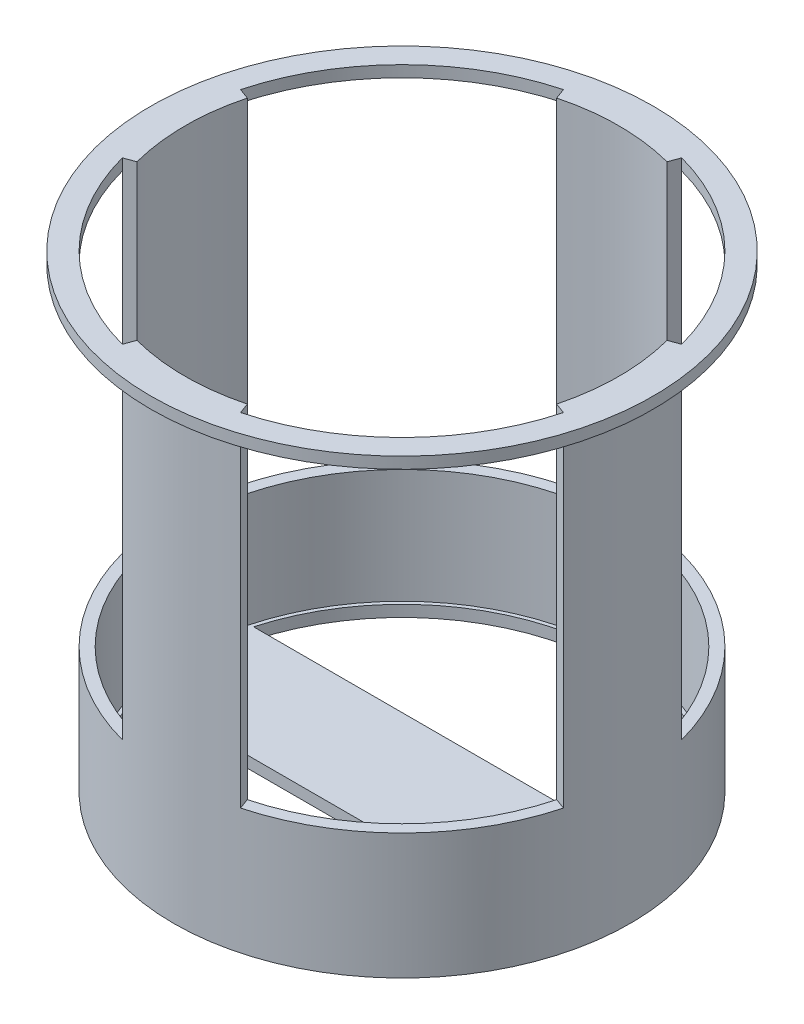
from build123d import *
from build123d.topology import SkipClean

# Parameters (mm, degrees)
SKETCH1_R           = 22
BOSS_EXTRUDE1_DEPTH = 1
SKETCH2_R           = 20
CUT_EXTRUDE1_DEPTH  = 1
SKETCH3_R           = 20
BOSS_EXTRUDE2_DEPTH = 1
BOSS_EXTRUDE3_REACH = 52.675
SKETCH5_R           = 20
SKETCH5_R_2         = 19.004147065
BOSS_EXTRUDE4_DEPTH = 10
CUT_EXTRUDE2_DEPTH  = 10


with BuildPart() as part:
    # Sketch1 → Boss-Extrude1 (new body)
    with BuildSketch(Plane(origin=(0, 0, 0), x_dir=(1, 0, 0), z_dir=(0, 1, 0))):
        with Locations(Location((0, 0, 0), (0, 0, 270))):
            Circle(SKETCH1_R)
    extrude(amount=BOSS_EXTRUDE1_DEPTH)

    # Sketch2 → Cut-Extrude1 (cut)
    with BuildSketch(Plane(origin=(0, 1, 0), x_dir=(1, 0, 0), z_dir=(0, 1, 0))):
        with Locations(Location((0, 0, 0), (0, 0, 270))):
            Circle(SKETCH2_R)
    extrude(amount=-CUT_EXTRUDE1_DEPTH, mode=Mode.SUBTRACT)

    # Boss-Extrude3: up to this face of the body (flat: up to its plane)
    boss_extrude3_end = Plane(part.part.faces().sort_by_distance((0, 1, -21.377746033))[0])
    # Sketch4 → Boss-Extrude3 (add, up to the picked face)
    with BuildSketch(Plane(origin=(0, -39, 0), x_dir=(1, 0, 0), z_dir=(0, 1, 0)), mode=Mode.PRIVATE) as boss_extrude3_sk1:
        with BuildLine():
            Line((-5.176380902, 19.318516526), (-4.834360759, 18.378823905))
            ThreePointArc((-4.834360759, 18.378823905), (-2.437308738, 18.847061792), (0, 19.004005159))
            ThreePointArc((0, 19.004005159), (2.437764249, 18.84700288), (4.835249142, 18.378590202))
            Line((4.835249142, 18.378590202), (5.176380902, 19.318516526))
            ThreePointArc((5.176380902, 19.318516526), (2.610523844, 19.828897227), (0, 20))
            ThreePointArc((0, 20), (-2.610523844, 19.828897227), (-5.176380902, 19.318516526))
        make_face()
    boss_extrude3_tool1 = split(extrude(boss_extrude3_sk1.sketch, amount=BOSS_EXTRUDE3_REACH, mode=Mode.PRIVATE), bisect_by=boss_extrude3_end, keep=Keep.BOTH, mode=Mode.PRIVATE)
    # Sketch4 → Boss-Extrude3 (add, up to the picked face)
    with BuildSketch(Plane(origin=(0, -39, 0), x_dir=(1, 0, 0), z_dir=(0, 1, 0)), mode=Mode.PRIVATE) as boss_extrude3_sk2:
        with BuildLine():
            Line((19.318516526, 5.176380902), (18.378823905, 4.834360759))
            ThreePointArc((18.378823905, 4.834360759), (18.847061792, 2.437308738), (19.004005159, 0))
            ThreePointArc((19.004005159, 0), (18.84700288, -2.437764249), (18.378590202, -4.835249142))
            Line((18.378590202, -4.835249142), (19.318516526, -5.176380902))
            ThreePointArc((19.318516526, -5.176380902), (19.828897227, -2.610523844), (20, 0))
            ThreePointArc((20, 0), (19.828897227, 2.610523844), (19.318516526, 5.176380902))
        make_face()
    boss_extrude3_tool2 = split(extrude(boss_extrude3_sk2.sketch, amount=BOSS_EXTRUDE3_REACH, mode=Mode.PRIVATE), bisect_by=boss_extrude3_end, keep=Keep.BOTH, mode=Mode.PRIVATE)
    # Sketch4 → Boss-Extrude3 (add, up to the picked face)
    with BuildSketch(Plane(origin=(0, -39, 0), x_dir=(1, 0, 0), z_dir=(0, 1, 0)), mode=Mode.PRIVATE) as boss_extrude3_sk3:
        with BuildLine():
            Line((5.176380902, -19.318516526), (4.834360759, -18.378823905))
            ThreePointArc((4.834360759, -18.378823905), (2.437308738, -18.847061792), (0, -19.004005159))
            ThreePointArc((0, -19.004005159), (-2.437764249, -18.84700288), (-4.835249142, -18.378590202))
            Line((-4.835249142, -18.378590202), (-5.176380902, -19.318516526))
            ThreePointArc((-5.176380902, -19.318516526), (-2.610523844, -19.828897227), (0, -20))
            ThreePointArc((0, -20), (2.610523844, -19.828897227), (5.176380902, -19.318516526))
        make_face()
    boss_extrude3_tool3 = split(extrude(boss_extrude3_sk3.sketch, amount=BOSS_EXTRUDE3_REACH, mode=Mode.PRIVATE), bisect_by=boss_extrude3_end, keep=Keep.BOTH, mode=Mode.PRIVATE)
    # Sketch4 → Boss-Extrude3 (add, up to the picked face)
    with BuildSketch(Plane(origin=(0, -39, 0), x_dir=(1, 0, 0), z_dir=(0, 1, 0)), mode=Mode.PRIVATE) as boss_extrude3_sk4:
        with BuildLine():
            Line((-19.318516526, -5.176380902), (-18.378823905, -4.834360759))
            ThreePointArc((-18.378823905, -4.834360759), (-18.847061792, -2.437308738), (-19.004005159, 0))
            ThreePointArc((-19.004005159, 0), (-18.84700288, 2.437764249), (-18.378590202, 4.835249142))
            Line((-18.378590202, 4.835249142), (-19.318516526, 5.176380902))
            ThreePointArc((-19.318516526, 5.176380902), (-19.828897227, 2.610523844), (-20, 0))
            ThreePointArc((-20, 0), (-19.828897227, -2.610523844), (-19.318516526, -5.176380902))
        make_face()
    boss_extrude3_tool4 = split(extrude(boss_extrude3_sk4.sketch, amount=BOSS_EXTRUDE3_REACH, mode=Mode.PRIVATE), bisect_by=boss_extrude3_end, keep=Keep.BOTH, mode=Mode.PRIVATE)


with BuildPart() as body_2:
    # Sketch3 → Boss-Extrude2 (new body)
    with BuildSketch(Plane(origin=(0, -40, 0), x_dir=(1, 0, 0), z_dir=(0, 1, 0))):
        with Locations(Location((0, 0, 0), (0, 0, 270))):
            Circle(SKETCH3_R)
    extrude(amount=BOSS_EXTRUDE2_DEPTH)


with BuildPart() as part_1:
    add(part.part)

    add(body_2.part)  # Boss-Extrude3 merges body 2
    add(boss_extrude3_tool1.solids().sort_by(Axis((0.000224, -39, -19.289315), (0, 1, 0)))[0])
    add(boss_extrude3_tool2.solids().sort_by(Axis((19.289315, -39, 0.000224), (0, 1, 0)))[0])
    add(boss_extrude3_tool3.solids().sort_by(Axis((-0.000224, -39, 19.289315), (0, 1, 0)))[0])
    add(boss_extrude3_tool4.solids().sort_by(Axis((-19.289315, -39, -0.000224), (0, 1, 0)))[0])

    # Sketch5 → Boss-Extrude4 (add)
    with SkipClean():  # the faces are left unmerged after this step: merging them gives an invalid solid
        with BuildSketch(Plane(origin=(0, -39, 0), x_dir=(1, 0, 0), z_dir=(0, 1, 0))):
            with Locations(Location((0, 0, 0), (0, 0, 105))):
                Circle(SKETCH5_R)
            Circle(SKETCH5_R_2, mode=Mode.SUBTRACT)
        extrude(amount=BOSS_EXTRUDE4_DEPTH)

    # Sketch6 → Cut-Extrude2 (cut)
    with SkipClean():  # the faces are left unmerged after this step: merging them gives an invalid solid
        with BuildSketch(Plane.XZ.offset(40)):
            with BuildLine():
                ThreePointArc((-18, 5), (0, 18.681541692), (18, 5))
                Line((18, 5), (-18, 5))
            make_face()
            with BuildLine():
                Line((-18, -5), (18, -5))
                ThreePointArc((18, -5), (0, -18.681541692), (-18, -5))
            make_face()
        extrude(amount=-CUT_EXTRUDE2_DEPTH, mode=Mode.SUBTRACT)


solid = part_1.part
